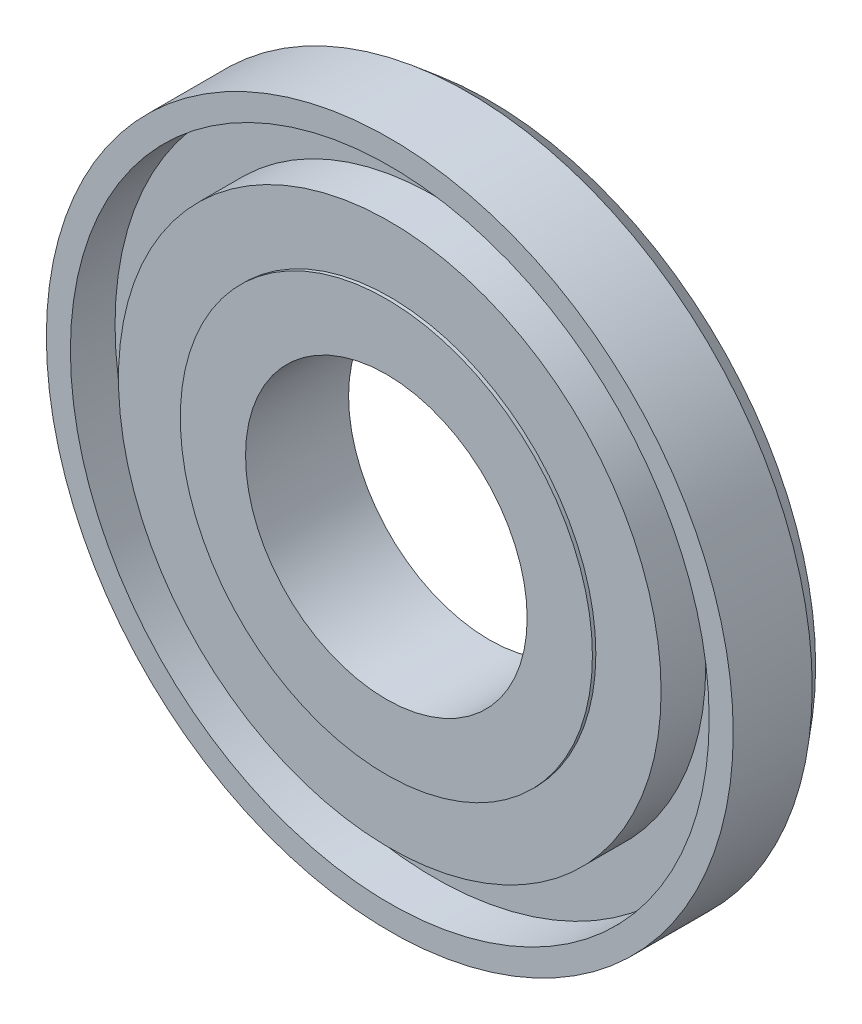
from build123d import *


with BuildPart() as part:
    # Esquisse1 → Révolution1 (revolve)
    with BuildSketch(Plane(origin=(0, 0, 0), x_dir=(1, 0, 0), z_dir=(0, 1, 0))):
        Polygon((39.5, -8), (46.5, -8), (46.5, -14.5), (50, -14.5), (50, -3), (47.5, 0), (20.5, 0), (20.5, -15), (30, -15), (30, -14.5), (39.5, -14.5), align=None)
    revolve(axis=Axis((0, 0, 0), (0, 0, 1)))


solid = part.part
